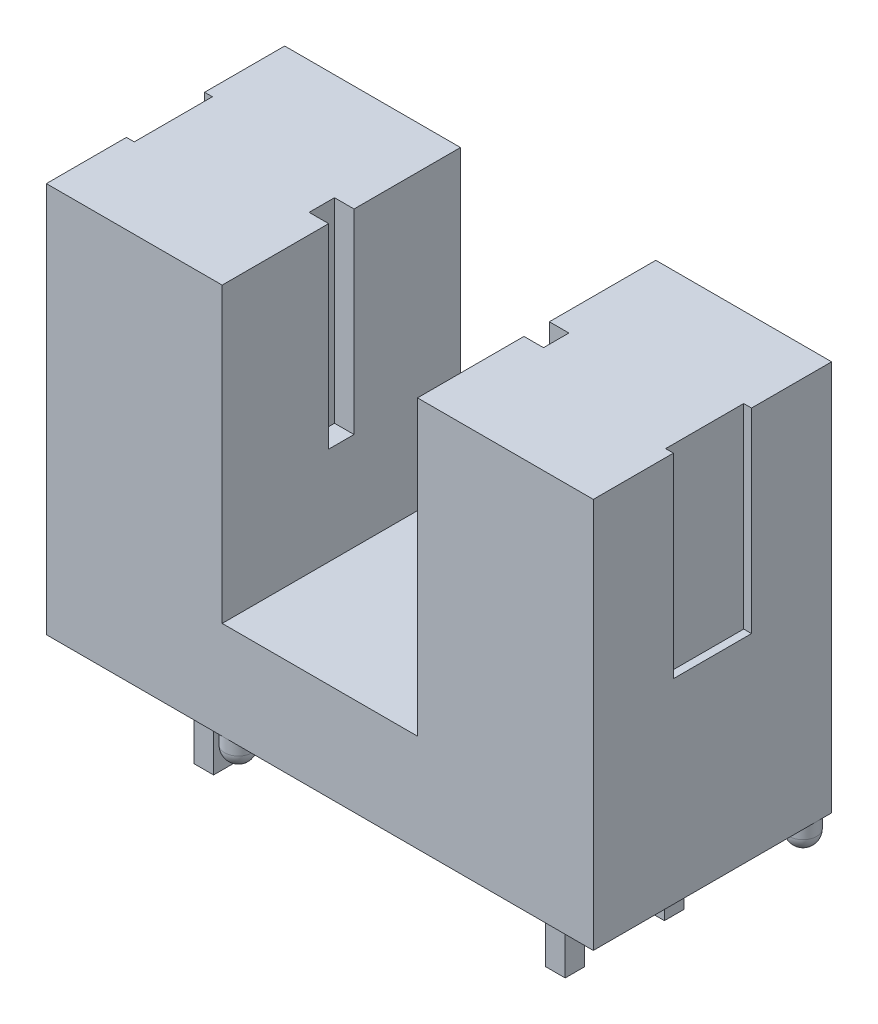
from build123d import *

# Parameters (mm, degrees)
EXTRUDE1_DEPTH           = 3.05
EXTRUDE1_DEPTH_BACK      = 3.05
EXTRUDE_THIN1_DEPTH      = 0.25
EXTRUDE_THIN1_DEPTH_BACK = 0.25
SKETCH2_W                = 0.5
SKETCH2_H                = 2.5
EXTRUDE_THIN2_DEPTH      = 0.25
EXTRUDE_THIN2_DEPTH_BACK = 0.25
SKETCH2_3_W              = 0.5
SKETCH2_3_H              = 2.5
EXTRUDE_THIN3_DEPTH      = 0.25
EXTRUDE_THIN3_DEPTH_BACK = 0.25
SKETCH3_W                = 0.5
SKETCH3_H                = 2.5
EXTRUDE_THIN4_DEPTH      = 0.25
EXTRUDE_THIN4_DEPTH_BACK = 0.25
SKETCH3_3_W              = 0.5
SKETCH3_3_H              = 2.5
SKETCH4_R                = 0.35
EXTRUDE2_DEPTH           = 0.7
FILLET1_R                = 0.35
SKETCH5_W                = 2
SKETCH5_H                = 5
CUT_EXTRUDE1_DEPTH       = 0.2
SKETCH6_W                = 2
SKETCH6_H                = 5
CUT_EXTRUDE2_DEPTH       = 0.2
SKETCH7_W                = 0.65
SKETCH7_H                = 5.045356776
CUT_EXTRUDE3_DEPTH       = 0.5
SKETCH8_W                = 0.65
SKETCH8_H                = 5.045356776
CUT_EXTRUDE4_DEPTH       = 0.5


with BuildPart() as part:
    # Sketch1 → Extrude1 (new, two sides: drawn at the far end of the back side and taken through both)
    with BuildSketch(Plane.XY.offset(-EXTRUDE1_DEPTH_BACK)):
        Polygon((2.5, 10), (7, 10), (7, 0), (-7, 0), (-7, 10), (-2.5, 10), (-2.5, 2.5), (2.5, 2.5), align=None)
    extrude(amount=EXTRUDE1_DEPTH + EXTRUDE1_DEPTH_BACK)

    # Sketch2 → Extrude-Thin1 (add, two sides: drawn at the far end of the back side and taken through both)
    with BuildSketch(Plane(origin=(4.5, 0, 0), x_dir=(0, 0, -1), z_dir=(1, 0, 0)).offset(-EXTRUDE_THIN1_DEPTH_BACK)):
        with Locations((1.27, -1.25)):
            Rectangle(SKETCH2_W, SKETCH2_H)
    extrude(amount=EXTRUDE_THIN1_DEPTH + EXTRUDE_THIN1_DEPTH_BACK)

    # Sketch2_3 → Extrude-Thin2 (add, two sides: drawn at the far end of the back side and taken through both)
    with BuildSketch(Plane(origin=(4.5, 0, 0), x_dir=(0, 0, -1), z_dir=(1, 0, 0)).offset(-EXTRUDE_THIN2_DEPTH_BACK)):
        with Locations((-1.27, -1.25)):
            Rectangle(SKETCH2_3_W, SKETCH2_3_H)
    extrude(amount=EXTRUDE_THIN2_DEPTH + EXTRUDE_THIN2_DEPTH_BACK)

    # Sketch3 → Extrude-Thin3 (add, two sides: drawn at the far end of the back side and taken through both)
    with BuildSketch(Plane(origin=(-4.5, 0, 0), x_dir=(0, 0, -1), z_dir=(1, 0, 0)).offset(-EXTRUDE_THIN3_DEPTH_BACK)):
        with Locations((1.27, -1.25)):
            Rectangle(SKETCH3_W, SKETCH3_H)
    extrude(amount=EXTRUDE_THIN3_DEPTH + EXTRUDE_THIN3_DEPTH_BACK)

    # Sketch3_3 → Extrude-Thin4 (add, two sides: drawn at the far end of the back side and taken through both)
    with BuildSketch(Plane(origin=(-4.5, 0, 0), x_dir=(0, 0, -1), z_dir=(1, 0, 0)).offset(-EXTRUDE_THIN4_DEPTH_BACK)):
        with Locations((-1.27, -1.25)):
            Rectangle(SKETCH3_3_W, SKETCH3_3_H)
    extrude(amount=EXTRUDE_THIN4_DEPTH + EXTRUDE_THIN4_DEPTH_BACK)

    # Sketch4 → Extrude2 (add)
    with BuildSketch(Plane(origin=(0, 0, 0), x_dir=(1, 0, 0), z_dir=(0, 1, 0))):
        with Locations((-2.45, -2.685779489)):
            Circle(SKETCH4_R)
        with Locations((6.630550891, 2.686987207)):
            Circle(SKETCH4_R)
    extrude(amount=-EXTRUDE2_DEPTH)

    # Fillet1
    fillet1_edges = [part.edges().sort_by_distance(p)[0] for p in [
        (6.280550891, -0.7, -2.686987207),
        (-2.8, -0.7, 2.685779489),
    ]]
    fillet(fillet1_edges, radius=FILLET1_R)

    # Sketch5 → Cut-Extrude1 (cut)
    with BuildSketch(Plane(origin=(7, 0, 0), x_dir=(0, 0, -1), z_dir=(1, 0, 0))):
        with Locations((0, 7.5)):
            Rectangle(SKETCH5_W, SKETCH5_H)
    extrude(amount=-CUT_EXTRUDE1_DEPTH, mode=Mode.SUBTRACT)

    # Sketch6 → Cut-Extrude2 (cut)
    with BuildSketch(Plane.ZY.offset(7)):
        with Locations((0, 7.5)):
            Rectangle(SKETCH6_W, SKETCH6_H)
    extrude(amount=-CUT_EXTRUDE2_DEPTH, mode=Mode.SUBTRACT)

    # Sketch7 → Cut-Extrude3 (cut)
    with BuildSketch(Plane.ZY.offset(-2.5)):
        with Locations((0, 7.522678388)):
            Rectangle(SKETCH7_W, SKETCH7_H)
    extrude(amount=-CUT_EXTRUDE3_DEPTH, mode=Mode.SUBTRACT)

    # Sketch8 → Cut-Extrude4 (cut)
    with BuildSketch(Plane(origin=(-2.5, 0, 0), x_dir=(0, 0, -1), z_dir=(1, 0, 0))):
        with Locations((0, 7.522678388)):
            Rectangle(SKETCH8_W, SKETCH8_H)
    extrude(amount=-CUT_EXTRUDE4_DEPTH, mode=Mode.SUBTRACT)


solid = part.part
